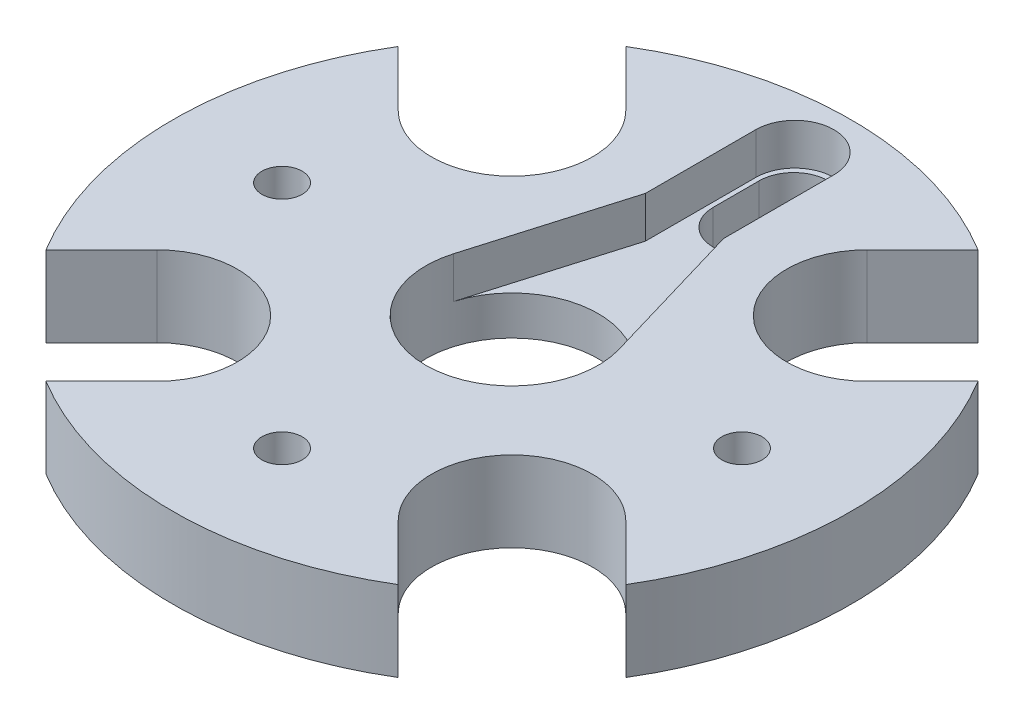
from build123d import *

# Parameters (mm, degrees)
SKETCH3_R           = 29.5
BOSS_EXTRUDE4_DEPTH = 7
CUT_EXTRUDE1_DEPTH  = 3.6
SKETCH5_R           = 7.5
CUT_EXTRUDE2_DEPTH  = 11.8
CUT_EXTRUDE3_DEPTH  = 15.8
SKETCH7_R           = 1.75
CUT_EXTRUDE4_DEPTH  = 20
SKETCH8_R           = 3.75
CUT_EXTRUDE5_DEPTH  = 2.4


with BuildPart() as part:
    # Sketch3 → Boss-Extrude4 (new body)
    with BuildSketch(Plane(origin=(0, 0, 0), x_dir=(1, 0, 0), z_dir=(0, 1, 0))):
        Circle(SKETCH3_R)
    extrude(amount=BOSS_EXTRUDE4_DEPTH)

    # Sketch4 → Cut-Extrude1 (cut)
    with BuildSketch(Plane(origin=(0, 7, 0), x_dir=(1, 0, 0), z_dir=(0, 1, 0))):
        with BuildLine():
            Line((-3.4, 24.6), (-3.4, 15))
            Line((-3.4, 15), (-7.194348327, 2.119281046))
            ThreePointArc((-7.194348327, 2.119281046), (0, -7.5), (7.194348327, 2.119281046))
            Line((7.194348327, 2.119281046), (3.4, 15))
            Line((3.4, 15), (3.4, 24.6))
            ThreePointArc((3.4, 24.6), (0, 28), (-3.4, 24.6))
        make_face()
    extrude(amount=-CUT_EXTRUDE1_DEPTH, mode=Mode.SUBTRACT)

    # Sketch5 → Cut-Extrude2 (cut)
    with BuildSketch(Plane(origin=(0, 7, 0), x_dir=(1, 0, 0), z_dir=(0, 1, 0))):
        Circle(SKETCH5_R)
        with BuildLine():
            Line((3, 24.5), (3, 20.5))
            ThreePointArc((3, 20.5), (0, 17.5), (-3, 20.5))
            Line((-3, 20.5), (-3, 24.5))
            ThreePointArc((-3, 24.5), (0, 27.5), (3, 24.5))
        make_face()
    extrude(amount=-CUT_EXTRUDE2_DEPTH, mode=Mode.SUBTRACT)

    # Sketch6 → Cut-Extrude3 (cut)
    with BuildSketch(Plane(origin=(0, 7, 0), x_dir=(1, 0, 0), z_dir=(0, 1, 0))):
        with BuildLine():
            Line((20.392959569, 10.493464633), (32.610697072, 22.711202135))
            Line((32.610697072, 22.711202135), (22.711202135, 32.610697072))
            Line((22.711202135, 32.610697072), (10.493464633, 20.392959569))
            ThreePointArc((10.493464633, 20.392959569), (10.493464633, 10.493464633), (20.392959569, 10.493464633))
        make_face()
        with BuildLine():
            Line((10.493464633, -20.392959569), (22.711202135, -32.610697072))
            Line((22.711202135, -32.610697072), (32.610697072, -22.711202135))
            Line((32.610697072, -22.711202135), (20.392959569, -10.493464633))
            ThreePointArc((20.392959569, -10.493464633), (10.493464633, -10.493464633), (10.493464633, -20.392959569))
        make_face()
        with BuildLine():
            Line((-20.392959569, -10.493464633), (-32.610697072, -22.711202135))
            Line((-32.610697072, -22.711202135), (-22.711202135, -32.610697072))
            Line((-22.711202135, -32.610697072), (-10.493464633, -20.392959569))
            ThreePointArc((-10.493464633, -20.392959569), (-10.493464633, -10.493464633), (-20.392959569, -10.493464633))
        make_face()
        with BuildLine():
            Line((-10.493464633, 20.392959569), (-22.711202135, 32.610697072))
            Line((-22.711202135, 32.610697072), (-32.610697072, 22.711202135))
            Line((-32.610697072, 22.711202135), (-20.392959569, 10.493464633))
            ThreePointArc((-20.392959569, 10.493464633), (-10.493464633, 10.493464633), (-10.493464633, 20.392959569))
        make_face()
    extrude(amount=-CUT_EXTRUDE3_DEPTH, mode=Mode.SUBTRACT)

    # Sketch7 → Cut-Extrude4 (cut)
    with BuildSketch(Plane(origin=(116.330739936, 17, -202.28312586), x_dir=(0.707106781, 0, 0.707106781), z_dir=(0, 1, 0))):
        with Locations((74.91965057, -211.151889461)):
            Circle(SKETCH7_R)
        with Locations((74.91965057, -239.436160708)):
            Circle(SKETCH7_R)
        with Locations((46.635379323, -239.436160708)):
            Circle(SKETCH7_R)
    extrude(amount=-CUT_EXTRUDE4_DEPTH, mode=Mode.SUBTRACT)

    # Sketch8 → Cut-Extrude5 (cut)
    with BuildSketch(Plane.XZ):
        with Locations((0, 20)):
            Circle(SKETCH8_R)
        with Locations((20, 0)):
            Circle(SKETCH8_R)
        with Locations((-20, 0)):
            Circle(SKETCH8_R)
    extrude(amount=-CUT_EXTRUDE5_DEPTH, mode=Mode.SUBTRACT)


solid = part.part
